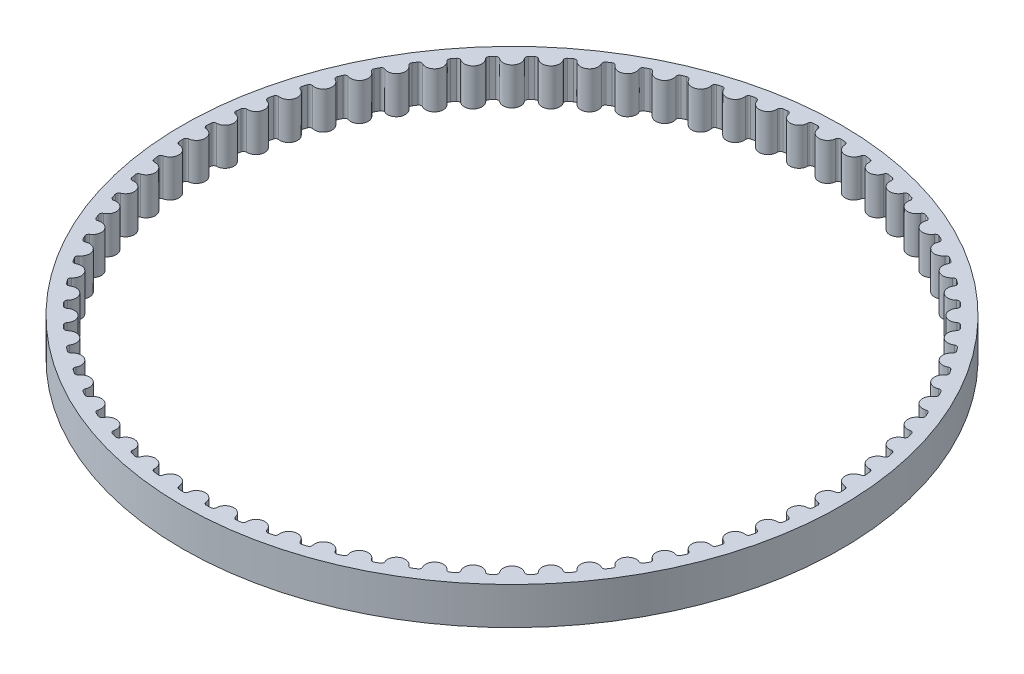
from build123d import *

# Parameters (mm, degrees)
SKETCH1_R           = 35.296467708
BOSS_EXTRUDE1_DEPTH = 4


with BuildPart() as part:
    # Sketch1 → Boss-Extrude1 (new body)
    with BuildSketch(Plane(origin=(0, 0, 0), x_dir=(1, 0, 0), z_dir=(0, 1, 0))):
        Circle(SKETCH1_R)
        with BuildLine():
            ThreePointArc((-1.718362432, -33.953012343), (-1.482905094, -33.964110604), (-1.247376465, -33.973576034))
            ThreePointArc((-1.247376465, -33.973576034), (-1.0405584, -33.900708364), (-0.93907482, -33.706326028))
            ThreePointArc((-0.93907482, -33.706326028), (0, -32.861621383), (0.93907482, -33.706326028))
            ThreePointArc((0.93907482, -33.706326028), (1.0405584, -33.900708364), (1.247376465, -33.973576034))
            ThreePointArc((1.247376465, -33.973576034), (1.482905094, -33.964110604), (1.718362432, -33.953012343))
            ThreePointArc((1.718362432, -33.953012343), (1.918042656, -33.862396574), (2.002198523, -33.659909045))
            ThreePointArc((2.002198523, -33.659909045), (2.864079019, -32.736572992), (3.873201237, -33.496217518))
            ThreePointArc((3.873201237, -33.496217518), (3.991240178, -33.681015294), (4.203622074, -33.735580298))
            ThreePointArc((4.203622074, -33.735580298), (4.437429479, -33.705623214), (4.671023553, -33.674045726))
            ThreePointArc((4.671023553, -33.674045726), (4.862046249, -33.5663715), (4.928233927, -33.35731983))
            ThreePointArc((4.928233927, -33.35731983), (5.706360668, -32.362379514), (6.777850254, -33.031182567))
            ThreePointArc((6.777850254, -33.031182567), (6.911546209, -33.20498936), (7.127875581, -33.240836426))
            ThreePointArc((7.127875581, -33.240836426), (7.358182346, -33.190615679), (7.588135365, -33.138799289))
            ThreePointArc((7.588135365, -33.138799289), (7.769046735, -33.01488607), (7.816762495, -32.800861268))
            ThreePointArc((7.816762495, -32.800861268), (8.505213467, -31.741888787), (9.630915738, -32.314760372))
            ThreePointArc((9.630915738, -32.314760372), (9.779251199, -32.476253407), (9.997881651, -32.493109717))
            ThreePointArc((9.997881651, -32.493109717), (10.222935002, -32.423007519), (10.447496885, -32.351346579))
            ThreePointArc((10.447496885, -32.351346579), (10.616920084, -32.212137422), (10.64580078, -31.994768347))
            ThreePointArc((10.64580078, -31.994768347), (11.239336455, -30.87982312), (12.410684138, -31.352403338))
            ThreePointArc((12.410684138, -31.352403338), (12.572530184, -31.500353556), (12.791797804, -31.498090824))
            ThreePointArc((12.791797804, -31.498090824), (13.009884951, -31.408640693), (13.227346645, -31.317680587))
            ThreePointArc((13.227346645, -31.317680587), (13.38399226, -31.164234959), (13.393818094, -30.94517592))
            ThreePointArc((13.393818094, -30.94517592), (13.887921307, -29.782743354), (15.095999738, -30.151435584))
            ThreePointArc((15.095999738, -30.151435584), (15.270124621, -30.284716994), (15.488360653, -30.26335244))
            ThreePointArc((15.488360653, -30.26335244), (15.697821819, -30.155235147), (15.90652831, -30.045668136))
            ThreePointArc((15.90652831, -30.045668136), (16.049204174, -29.87915385), (16.039900364, -29.660072019))
            ThreePointArc((16.039900364, -29.660072019), (16.430810691, -28.458998927), (17.666425664, -28.720997199))
            ThreePointArc((17.666425664, -28.720997199), (17.851504191, -28.83859545), (18.067047724, -28.798291671))
            ThreePointArc((18.067047724, -28.798291671), (18.266288785, -28.672330053), (18.46465169, -28.544990008))
            ThreePointArc((18.46465169, -28.544990008), (18.592271953, -28.366674338), (18.563909307, -28.14923706))
            ThreePointArc((18.563909307, -28.14923706), (18.848651685, -26.918664334), (20.102399424, -27.071974683))
            ThreePointArc((20.102399424, -27.071974683), (20.297023034, -27.172994781), (20.508233653, -27.114058513))
            ThreePointArc((20.508233653, -27.114058513), (20.695738263, -26.971211214), (20.882247922, -26.827067271))
            ThreePointArc((20.882247922, -26.827067271), (20.993841316, -26.638307307), (20.946635692, -26.424169411))
            ThreePointArc((20.946635692, -26.424169411), (21.123043059, -25.173462452), (22.385381787, -25.216918093))
            ThreePointArc((22.385381787, -25.216918093), (22.588069276, -25.300591214), (22.793339541, -25.223470998))
            ThreePointArc((22.793339541, -25.223470998), (22.967680677, -25.064825173), (23.140917638, -24.904974352))
            ThreePointArc((23.140917638, -24.904974352), (23.235634871, -24.707206672), (23.16994553, -24.497997877))
            ThreePointArc((23.16994553, -24.497997877), (23.23667532, -23.23667532), (24.497997877, -23.16994553))
            ThreePointArc((24.497997877, -23.16994553), (24.707206672, -23.235634871), (24.904974352, -23.140917638))
            ThreePointArc((24.904974352, -23.140917638), (25.064825173, -22.967680677), (25.223470998, -22.793339541))
            ThreePointArc((25.223470998, -22.793339541), (25.300591214, -22.588069276), (25.216918093, -22.385381787))
            ThreePointArc((25.216918093, -22.385381787), (25.173462452, -21.123043059), (26.424169411, -20.946635692))
            ThreePointArc((26.424169411, -20.946635692), (26.638307307, -20.993841316), (26.827067271, -20.882247922))
            ThreePointArc((26.827067271, -20.882247922), (26.971211214, -20.695738263), (27.114058513, -20.508233653))
            ThreePointArc((27.114058513, -20.508233653), (27.172994781, -20.297023034), (27.071974683, -20.102399424))
            ThreePointArc((27.071974683, -20.102399424), (26.918664334, -18.848651685), (28.14923706, -18.563909307))
            ThreePointArc((28.14923706, -18.563909307), (28.366674338, -18.592271953), (28.544990008, -18.46465169))
            ThreePointArc((28.544990008, -18.46465169), (28.672330053, -18.266288785), (28.798291671, -18.067047724))
            ThreePointArc((28.798291671, -18.067047724), (28.83859545, -17.851504191), (28.720997199, -17.666425664))
            ThreePointArc((28.720997199, -17.666425664), (28.458998927, -16.430810691), (29.660072019, -16.039900364))
            ThreePointArc((29.660072019, -16.039900364), (29.87915385, -16.049204174), (30.045668136, -15.90652831))
            ThreePointArc((30.045668136, -15.90652831), (30.155235147, -15.697821819), (30.26335244, -15.488360653))
            ThreePointArc((30.26335244, -15.488360653), (30.284716994, -15.270124621), (30.151435584, -15.095999738))
            ThreePointArc((30.151435584, -15.095999738), (29.782743354, -13.887921307), (30.94517592, -13.393818094))
            ThreePointArc((30.94517592, -13.393818094), (31.164234959, -13.38399226), (31.317680587, -13.227346645))
            ThreePointArc((31.317680587, -13.227346645), (31.408640693, -13.009884951), (31.498090824, -12.791797804))
            ThreePointArc((31.498090824, -12.791797804), (31.500353556, -12.572530184), (31.352403338, -12.410684138))
            ThreePointArc((31.352403338, -12.410684138), (30.87982312, -11.239336455), (31.994768347, -10.64580078))
            ThreePointArc((31.994768347, -10.64580078), (32.212137422, -10.616920084), (32.351346579, -10.447496885))
            ThreePointArc((32.351346579, -10.447496885), (32.423007519, -10.222935002), (32.493109717, -9.997881651))
            ThreePointArc((32.493109717, -9.997881651), (32.476253407, -9.779251199), (32.314760372, -9.630915738))
            ThreePointArc((32.314760372, -9.630915738), (31.741888787, -8.505213467), (32.800861268, -7.816762495))
            ThreePointArc((32.800861268, -7.816762495), (33.01488607, -7.769046735), (33.138799289, -7.588135365))
            ThreePointArc((33.138799289, -7.588135365), (33.190615679, -7.358182346), (33.240836426, -7.127875581))
            ThreePointArc((33.240836426, -7.127875581), (33.20498936, -6.911546209), (33.031182567, -6.777850254))
            ThreePointArc((33.031182567, -6.777850254), (32.362379514, -5.706360668), (33.35731983, -4.928233927))
            ThreePointArc((33.35731983, -4.928233927), (33.5663715, -4.862046249), (33.674045726, -4.671023553))
            ThreePointArc((33.674045726, -4.671023553), (33.705623214, -4.437429479), (33.735580298, -4.203622074))
            ThreePointArc((33.735580298, -4.203622074), (33.681015294, -3.991240178), (33.496217518, -3.873201237))
            ThreePointArc((33.496217518, -3.873201237), (32.736572992, -2.864079019), (33.659909045, -2.002198523))
            ThreePointArc((33.659909045, -2.002198523), (33.862396574, -1.918042656), (33.953012343, -1.718362432))
            ThreePointArc((33.953012343, -1.718362432), (33.964110604, -1.482905094), (33.973576034, -1.247376465))
            ThreePointArc((33.973576034, -1.247376465), (33.900708364, -1.0405584), (33.706326028, -0.93907482))
            ThreePointArc((33.706326028, -0.93907482), (32.861621383, 0), (33.706326028, 0.93907482))
            ThreePointArc((33.706326028, 0.93907482), (33.900708364, 1.0405584), (33.973576034, 1.247376465))
            ThreePointArc((33.973576034, 1.247376465), (33.964110604, 1.482905094), (33.953012343, 1.718362432))
            ThreePointArc((33.953012343, 1.718362432), (33.862396574, 1.918042656), (33.659909045, 2.002198523))
            ThreePointArc((33.659909045, 2.002198523), (32.736572992, 2.864079019), (33.496217518, 3.873201237))
            ThreePointArc((33.496217518, 3.873201237), (33.681015294, 3.991240178), (33.735580298, 4.203622074))
            ThreePointArc((33.735580298, 4.203622074), (33.705623214, 4.437429479), (33.674045726, 4.671023553))
            ThreePointArc((33.674045726, 4.671023553), (33.5663715, 4.862046249), (33.35731983, 4.928233927))
            ThreePointArc((33.35731983, 4.928233927), (32.362379514, 5.706360668), (33.031182567, 6.777850254))
            ThreePointArc((33.031182567, 6.777850254), (33.20498936, 6.911546209), (33.240836426, 7.127875581))
            ThreePointArc((33.240836426, 7.127875581), (33.190615679, 7.358182346), (33.138799289, 7.588135365))
            ThreePointArc((33.138799289, 7.588135365), (33.01488607, 7.769046735), (32.800861268, 7.816762495))
            ThreePointArc((32.800861268, 7.816762495), (31.741888787, 8.505213467), (32.314760372, 9.630915738))
            ThreePointArc((32.314760372, 9.630915738), (32.476253407, 9.779251199), (32.493109717, 9.997881651))
            ThreePointArc((32.493109717, 9.997881651), (32.423007519, 10.222935002), (32.351346579, 10.447496885))
            ThreePointArc((32.351346579, 10.447496885), (32.212137422, 10.616920084), (31.994768347, 10.64580078))
            ThreePointArc((31.994768347, 10.64580078), (30.87982312, 11.239336455), (31.352403338, 12.410684138))
            ThreePointArc((31.352403338, 12.410684138), (31.500353556, 12.572530184), (31.498090824, 12.791797804))
            ThreePointArc((31.498090824, 12.791797804), (31.408640693, 13.009884951), (31.317680587, 13.227346645))
            ThreePointArc((31.317680587, 13.227346645), (31.164234959, 13.38399226), (30.94517592, 13.393818094))
            ThreePointArc((30.94517592, 13.393818094), (29.782743354, 13.887921307), (30.151435584, 15.095999738))
            ThreePointArc((30.151435584, 15.095999738), (30.284716994, 15.270124621), (30.26335244, 15.488360653))
            ThreePointArc((30.26335244, 15.488360653), (30.155235147, 15.697821819), (30.045668136, 15.90652831))
            ThreePointArc((30.045668136, 15.90652831), (29.87915385, 16.049204174), (29.660072019, 16.039900364))
            ThreePointArc((29.660072019, 16.039900364), (28.458998927, 16.430810691), (28.720997199, 17.666425664))
            ThreePointArc((28.720997199, 17.666425664), (28.83859545, 17.851504191), (28.798291671, 18.067047724))
            ThreePointArc((28.798291671, 18.067047724), (28.672330053, 18.266288785), (28.544990008, 18.46465169))
            ThreePointArc((28.544990008, 18.46465169), (28.366674338, 18.592271953), (28.14923706, 18.563909307))
            ThreePointArc((28.14923706, 18.563909307), (26.918664334, 18.848651685), (27.071974683, 20.102399424))
            ThreePointArc((27.071974683, 20.102399424), (27.172994781, 20.297023034), (27.114058513, 20.508233653))
            ThreePointArc((27.114058513, 20.508233653), (26.971211214, 20.695738263), (26.827067271, 20.882247922))
            ThreePointArc((26.827067271, 20.882247922), (26.638307307, 20.993841316), (26.424169411, 20.946635692))
            ThreePointArc((26.424169411, 20.946635692), (25.173462452, 21.123043059), (25.216918093, 22.385381787))
            ThreePointArc((25.216918093, 22.385381787), (25.300591214, 22.588069276), (25.223470998, 22.793339541))
            ThreePointArc((25.223470998, 22.793339541), (25.064825173, 22.967680677), (24.904974352, 23.140917638))
            ThreePointArc((24.904974352, 23.140917638), (24.707206672, 23.235634871), (24.497997877, 23.16994553))
            ThreePointArc((24.497997877, 23.16994553), (23.23667532, 23.23667532), (23.16994553, 24.497997877))
            ThreePointArc((23.16994553, 24.497997877), (23.235634871, 24.707206672), (23.140917638, 24.904974352))
            ThreePointArc((23.140917638, 24.904974352), (22.967680677, 25.064825173), (22.793339541, 25.223470998))
            ThreePointArc((22.793339541, 25.223470998), (22.588069276, 25.300591214), (22.385381787, 25.216918093))
            ThreePointArc((22.385381787, 25.216918093), (21.123043059, 25.173462452), (20.946635692, 26.424169411))
            ThreePointArc((20.946635692, 26.424169411), (20.993841316, 26.638307307), (20.882247922, 26.827067271))
            ThreePointArc((20.882247922, 26.827067271), (20.695738263, 26.971211214), (20.508233653, 27.114058513))
            ThreePointArc((20.508233653, 27.114058513), (20.297023034, 27.172994781), (20.102399424, 27.071974683))
            ThreePointArc((20.102399424, 27.071974683), (18.848651685, 26.918664334), (18.563909307, 28.14923706))
            ThreePointArc((18.563909307, 28.14923706), (18.592271953, 28.366674338), (18.46465169, 28.544990008))
            ThreePointArc((18.46465169, 28.544990008), (18.266288785, 28.672330053), (18.067047724, 28.798291671))
            ThreePointArc((18.067047724, 28.798291671), (17.851504191, 28.83859545), (17.666425664, 28.720997199))
            ThreePointArc((17.666425664, 28.720997199), (16.430810691, 28.458998927), (16.039900364, 29.660072019))
            ThreePointArc((16.039900364, 29.660072019), (16.049204174, 29.87915385), (15.90652831, 30.045668136))
            ThreePointArc((15.90652831, 30.045668136), (15.697821819, 30.155235147), (15.488360653, 30.26335244))
            ThreePointArc((15.488360653, 30.26335244), (15.270124621, 30.284716994), (15.095999738, 30.151435584))
            ThreePointArc((15.095999738, 30.151435584), (13.887921307, 29.782743354), (13.393818094, 30.94517592))
            ThreePointArc((13.393818094, 30.94517592), (13.38399226, 31.164234959), (13.227346645, 31.317680587))
            ThreePointArc((13.227346645, 31.317680587), (13.009884951, 31.408640693), (12.791797804, 31.498090824))
            ThreePointArc((12.791797804, 31.498090824), (12.572530184, 31.500353556), (12.410684138, 31.352403338))
            ThreePointArc((12.410684138, 31.352403338), (11.239336455, 30.87982312), (10.64580078, 31.994768347))
            ThreePointArc((10.64580078, 31.994768347), (10.616920084, 32.212137422), (10.447496885, 32.351346579))
            ThreePointArc((10.447496885, 32.351346579), (10.222935002, 32.423007519), (9.997881651, 32.493109717))
            ThreePointArc((9.997881651, 32.493109717), (9.779251199, 32.476253407), (9.630915738, 32.314760372))
            ThreePointArc((9.630915738, 32.314760372), (8.505213467, 31.741888787), (7.816762495, 32.800861268))
            ThreePointArc((7.816762495, 32.800861268), (7.769046735, 33.01488607), (7.588135365, 33.138799289))
            ThreePointArc((7.588135365, 33.138799289), (7.358182346, 33.190615679), (7.127875581, 33.240836426))
            ThreePointArc((7.127875581, 33.240836426), (6.911546209, 33.20498936), (6.777850254, 33.031182567))
            ThreePointArc((6.777850254, 33.031182567), (5.706360668, 32.362379514), (4.928233927, 33.35731983))
            ThreePointArc((4.928233927, 33.35731983), (4.862046249, 33.5663715), (4.671023553, 33.674045726))
            ThreePointArc((4.671023553, 33.674045726), (4.437429479, 33.705623214), (4.203622074, 33.735580298))
            ThreePointArc((4.203622074, 33.735580298), (3.991240178, 33.681015294), (3.873201237, 33.496217518))
            ThreePointArc((3.873201237, 33.496217518), (2.864079019, 32.736572992), (2.002198523, 33.659909045))
            ThreePointArc((2.002198523, 33.659909045), (1.918042656, 33.862396574), (1.718362432, 33.953012343))
            ThreePointArc((1.718362432, 33.953012343), (1.482905094, 33.964110604), (1.247376465, 33.973576034))
            ThreePointArc((1.247376465, 33.973576034), (1.0405584, 33.900708364), (0.93907482, 33.706326028))
            ThreePointArc((0.93907482, 33.706326028), (0, 32.861621383), (-0.93907482, 33.706326028))
            ThreePointArc((-0.93907482, 33.706326028), (-1.0405584, 33.900708364), (-1.247376465, 33.973576034))
            ThreePointArc((-1.247376465, 33.973576034), (-1.482905094, 33.964110604), (-1.718362432, 33.953012343))
            ThreePointArc((-1.718362432, 33.953012343), (-1.918042656, 33.862396574), (-2.002198523, 33.659909045))
            ThreePointArc((-2.002198523, 33.659909045), (-2.864079019, 32.736572992), (-3.873201237, 33.496217518))
            ThreePointArc((-3.873201237, 33.496217518), (-3.991240178, 33.681015294), (-4.203622074, 33.735580298))
            ThreePointArc((-4.203622074, 33.735580298), (-4.437429479, 33.705623214), (-4.671023553, 33.674045726))
            ThreePointArc((-4.671023553, 33.674045726), (-4.862046249, 33.5663715), (-4.928233927, 33.35731983))
            ThreePointArc((-4.928233927, 33.35731983), (-5.706360668, 32.362379514), (-6.777850254, 33.031182567))
            ThreePointArc((-6.777850254, 33.031182567), (-6.911546209, 33.20498936), (-7.127875581, 33.240836426))
            ThreePointArc((-7.127875581, 33.240836426), (-7.358182346, 33.190615679), (-7.588135365, 33.138799289))
            ThreePointArc((-7.588135365, 33.138799289), (-7.769046735, 33.01488607), (-7.816762495, 32.800861268))
            ThreePointArc((-7.816762495, 32.800861268), (-8.505213467, 31.741888787), (-9.630915738, 32.314760372))
            ThreePointArc((-9.630915738, 32.314760372), (-9.779251199, 32.476253407), (-9.997881651, 32.493109717))
            ThreePointArc((-9.997881651, 32.493109717), (-10.222935002, 32.423007519), (-10.447496885, 32.351346579))
            ThreePointArc((-10.447496885, 32.351346579), (-10.616920084, 32.212137422), (-10.64580078, 31.994768347))
            ThreePointArc((-10.64580078, 31.994768347), (-11.239336455, 30.87982312), (-12.410684138, 31.352403338))
            ThreePointArc((-12.410684138, 31.352403338), (-12.572530184, 31.500353556), (-12.791797804, 31.498090824))
            ThreePointArc((-12.791797804, 31.498090824), (-13.009884951, 31.408640693), (-13.227346645, 31.317680587))
            ThreePointArc((-13.227346645, 31.317680587), (-13.38399226, 31.164234959), (-13.393818094, 30.94517592))
            ThreePointArc((-13.393818094, 30.94517592), (-13.887921307, 29.782743354), (-15.095999738, 30.151435584))
            ThreePointArc((-15.095999738, 30.151435584), (-15.270124621, 30.284716994), (-15.488360653, 30.26335244))
            ThreePointArc((-15.488360653, 30.26335244), (-15.697821819, 30.155235147), (-15.90652831, 30.045668136))
            ThreePointArc((-15.90652831, 30.045668136), (-16.049204174, 29.87915385), (-16.039900364, 29.660072019))
            ThreePointArc((-16.039900364, 29.660072019), (-16.430810691, 28.458998927), (-17.666425664, 28.720997199))
            ThreePointArc((-17.666425664, 28.720997199), (-17.851504191, 28.83859545), (-18.067047724, 28.798291671))
            ThreePointArc((-18.067047724, 28.798291671), (-18.266288785, 28.672330053), (-18.46465169, 28.544990008))
            ThreePointArc((-18.46465169, 28.544990008), (-18.592271953, 28.366674338), (-18.563909307, 28.14923706))
            ThreePointArc((-18.563909307, 28.14923706), (-18.848651685, 26.918664334), (-20.102399424, 27.071974683))
            ThreePointArc((-20.102399424, 27.071974683), (-20.297023034, 27.172994781), (-20.508233653, 27.114058513))
            ThreePointArc((-20.508233653, 27.114058513), (-20.695738263, 26.971211214), (-20.882247922, 26.827067271))
            ThreePointArc((-20.882247922, 26.827067271), (-20.993841316, 26.638307307), (-20.946635692, 26.424169411))
            ThreePointArc((-20.946635692, 26.424169411), (-21.123043059, 25.173462452), (-22.385381787, 25.216918093))
            ThreePointArc((-22.385381787, 25.216918093), (-22.588069276, 25.300591214), (-22.793339541, 25.223470998))
            ThreePointArc((-22.793339541, 25.223470998), (-22.967680677, 25.064825173), (-23.140917638, 24.904974352))
            ThreePointArc((-23.140917638, 24.904974352), (-23.235634871, 24.707206672), (-23.16994553, 24.497997877))
            ThreePointArc((-23.16994553, 24.497997877), (-23.23667532, 23.23667532), (-24.497997877, 23.16994553))
            ThreePointArc((-24.497997877, 23.16994553), (-24.707206672, 23.235634871), (-24.904974352, 23.140917638))
            ThreePointArc((-24.904974352, 23.140917638), (-25.064825173, 22.967680677), (-25.223470998, 22.793339541))
            ThreePointArc((-25.223470998, 22.793339541), (-25.300591214, 22.588069276), (-25.216918093, 22.385381787))
            ThreePointArc((-25.216918093, 22.385381787), (-25.173462452, 21.123043059), (-26.424169411, 20.946635692))
            ThreePointArc((-26.424169411, 20.946635692), (-26.638307307, 20.993841316), (-26.827067271, 20.882247922))
            ThreePointArc((-26.827067271, 20.882247922), (-26.971211214, 20.695738263), (-27.114058513, 20.508233653))
            ThreePointArc((-27.114058513, 20.508233653), (-27.172994781, 20.297023034), (-27.071974683, 20.102399424))
            ThreePointArc((-27.071974683, 20.102399424), (-26.918664334, 18.848651685), (-28.14923706, 18.563909307))
            ThreePointArc((-28.14923706, 18.563909307), (-28.366674338, 18.592271953), (-28.544990008, 18.46465169))
            ThreePointArc((-28.544990008, 18.46465169), (-28.672330053, 18.266288785), (-28.798291671, 18.067047724))
            ThreePointArc((-28.798291671, 18.067047724), (-28.83859545, 17.851504191), (-28.720997199, 17.666425664))
            ThreePointArc((-28.720997199, 17.666425664), (-28.458998927, 16.430810691), (-29.660072019, 16.039900364))
            ThreePointArc((-29.660072019, 16.039900364), (-29.87915385, 16.049204174), (-30.045668136, 15.90652831))
            ThreePointArc((-30.045668136, 15.90652831), (-30.155235147, 15.697821819), (-30.26335244, 15.488360653))
            ThreePointArc((-30.26335244, 15.488360653), (-30.284716994, 15.270124621), (-30.151435584, 15.095999738))
            ThreePointArc((-30.151435584, 15.095999738), (-29.782743354, 13.887921307), (-30.94517592, 13.393818094))
            ThreePointArc((-30.94517592, 13.393818094), (-31.164234959, 13.38399226), (-31.317680587, 13.227346645))
            ThreePointArc((-31.317680587, 13.227346645), (-31.408640693, 13.009884951), (-31.498090824, 12.791797804))
            ThreePointArc((-31.498090824, 12.791797804), (-31.500353556, 12.572530184), (-31.352403338, 12.410684138))
            ThreePointArc((-31.352403338, 12.410684138), (-30.87982312, 11.239336455), (-31.994768347, 10.64580078))
            ThreePointArc((-31.994768347, 10.64580078), (-32.212137422, 10.616920084), (-32.351346579, 10.447496885))
            ThreePointArc((-32.351346579, 10.447496885), (-32.423007519, 10.222935002), (-32.493109717, 9.997881651))
            ThreePointArc((-32.493109717, 9.997881651), (-32.476253407, 9.779251199), (-32.314760372, 9.630915738))
            ThreePointArc((-32.314760372, 9.630915738), (-31.741888787, 8.505213467), (-32.800861268, 7.816762495))
            ThreePointArc((-32.800861268, 7.816762495), (-33.01488607, 7.769046735), (-33.138799289, 7.588135365))
            ThreePointArc((-33.138799289, 7.588135365), (-33.190615679, 7.358182346), (-33.240836426, 7.127875581))
            ThreePointArc((-33.240836426, 7.127875581), (-33.20498936, 6.911546209), (-33.031182567, 6.777850254))
            ThreePointArc((-33.031182567, 6.777850254), (-32.362379514, 5.706360668), (-33.35731983, 4.928233927))
            ThreePointArc((-33.35731983, 4.928233927), (-33.5663715, 4.862046249), (-33.674045726, 4.671023553))
            ThreePointArc((-33.674045726, 4.671023553), (-33.705623214, 4.437429479), (-33.735580298, 4.203622074))
            ThreePointArc((-33.735580298, 4.203622074), (-33.681015294, 3.991240178), (-33.496217518, 3.873201237))
            ThreePointArc((-33.496217518, 3.873201237), (-32.736572992, 2.864079019), (-33.659909045, 2.002198523))
            ThreePointArc((-33.659909045, 2.002198523), (-33.862396574, 1.918042656), (-33.953012343, 1.718362432))
            ThreePointArc((-33.953012343, 1.718362432), (-33.964110604, 1.482905094), (-33.973576034, 1.247376465))
            ThreePointArc((-33.973576034, 1.247376465), (-33.900708364, 1.0405584), (-33.706326028, 0.93907482))
            ThreePointArc((-33.706326028, 0.93907482), (-32.861621383, 0), (-33.706326028, -0.93907482))
            ThreePointArc((-33.706326028, -0.93907482), (-33.900708364, -1.0405584), (-33.973576034, -1.247376465))
            ThreePointArc((-33.973576034, -1.247376465), (-33.964110604, -1.482905094), (-33.953012343, -1.718362432))
            ThreePointArc((-33.953012343, -1.718362432), (-33.862396574, -1.918042656), (-33.659909045, -2.002198523))
            ThreePointArc((-33.659909045, -2.002198523), (-32.736572992, -2.864079019), (-33.496217518, -3.873201237))
            ThreePointArc((-33.496217518, -3.873201237), (-33.681015294, -3.991240178), (-33.735580298, -4.203622074))
            ThreePointArc((-33.735580298, -4.203622074), (-33.705623214, -4.437429479), (-33.674045726, -4.671023553))
            ThreePointArc((-33.674045726, -4.671023553), (-33.5663715, -4.862046249), (-33.35731983, -4.928233927))
            ThreePointArc((-33.35731983, -4.928233927), (-32.362379514, -5.706360668), (-33.031182567, -6.777850254))
            ThreePointArc((-33.031182567, -6.777850254), (-33.20498936, -6.911546209), (-33.240836426, -7.127875581))
            ThreePointArc((-33.240836426, -7.127875581), (-33.190615679, -7.358182346), (-33.138799289, -7.588135365))
            ThreePointArc((-33.138799289, -7.588135365), (-33.01488607, -7.769046735), (-32.800861268, -7.816762495))
            ThreePointArc((-32.800861268, -7.816762495), (-31.741888787, -8.505213467), (-32.314760372, -9.630915738))
            ThreePointArc((-32.314760372, -9.630915738), (-32.476253407, -9.779251199), (-32.493109717, -9.997881651))
            ThreePointArc((-32.493109717, -9.997881651), (-32.423007519, -10.222935002), (-32.351346579, -10.447496885))
            ThreePointArc((-32.351346579, -10.447496885), (-32.212137422, -10.616920084), (-31.994768347, -10.64580078))
            ThreePointArc((-31.994768347, -10.64580078), (-30.87982312, -11.239336455), (-31.352403338, -12.410684138))
            ThreePointArc((-31.352403338, -12.410684138), (-31.500353556, -12.572530184), (-31.498090824, -12.791797804))
            ThreePointArc((-31.498090824, -12.791797804), (-31.408640693, -13.009884951), (-31.317680587, -13.227346645))
            ThreePointArc((-31.317680587, -13.227346645), (-31.164234959, -13.38399226), (-30.94517592, -13.393818094))
            ThreePointArc((-30.94517592, -13.393818094), (-29.782743354, -13.887921307), (-30.151435584, -15.095999738))
            ThreePointArc((-30.151435584, -15.095999738), (-30.284716994, -15.270124621), (-30.26335244, -15.488360653))
            ThreePointArc((-30.26335244, -15.488360653), (-30.155235147, -15.697821819), (-30.045668136, -15.90652831))
            ThreePointArc((-30.045668136, -15.90652831), (-29.87915385, -16.049204174), (-29.660072019, -16.039900364))
            ThreePointArc((-29.660072019, -16.039900364), (-28.458998927, -16.430810691), (-28.720997199, -17.666425664))
            ThreePointArc((-28.720997199, -17.666425664), (-28.83859545, -17.851504191), (-28.798291671, -18.067047724))
            ThreePointArc((-28.798291671, -18.067047724), (-28.672330053, -18.266288785), (-28.544990008, -18.46465169))
            ThreePointArc((-28.544990008, -18.46465169), (-28.366674338, -18.592271953), (-28.14923706, -18.563909307))
            ThreePointArc((-28.14923706, -18.563909307), (-26.918664334, -18.848651685), (-27.071974683, -20.102399424))
            ThreePointArc((-27.071974683, -20.102399424), (-27.172994781, -20.297023034), (-27.114058513, -20.508233653))
            ThreePointArc((-27.114058513, -20.508233653), (-26.971211214, -20.695738263), (-26.827067271, -20.882247922))
            ThreePointArc((-26.827067271, -20.882247922), (-26.638307307, -20.993841316), (-26.424169411, -20.946635692))
            ThreePointArc((-26.424169411, -20.946635692), (-25.173462452, -21.123043059), (-25.216918093, -22.385381787))
            ThreePointArc((-25.216918093, -22.385381787), (-25.300591214, -22.588069276), (-25.223470998, -22.793339541))
            ThreePointArc((-25.223470998, -22.793339541), (-25.064825173, -22.967680677), (-24.904974352, -23.140917638))
            ThreePointArc((-24.904974352, -23.140917638), (-24.707206672, -23.235634871), (-24.497997877, -23.16994553))
            ThreePointArc((-24.497997877, -23.16994553), (-23.23667532, -23.23667532), (-23.16994553, -24.497997877))
            ThreePointArc((-23.16994553, -24.497997877), (-23.235634871, -24.707206672), (-23.140917638, -24.904974352))
            ThreePointArc((-23.140917638, -24.904974352), (-22.967680677, -25.064825173), (-22.793339541, -25.223470998))
            ThreePointArc((-22.793339541, -25.223470998), (-22.588069276, -25.300591214), (-22.385381787, -25.216918093))
            ThreePointArc((-22.385381787, -25.216918093), (-21.123043059, -25.173462452), (-20.946635692, -26.424169411))
            ThreePointArc((-20.946635692, -26.424169411), (-20.993841316, -26.638307307), (-20.882247922, -26.827067271))
            ThreePointArc((-20.882247922, -26.827067271), (-20.695738263, -26.971211214), (-20.508233653, -27.114058513))
            ThreePointArc((-20.508233653, -27.114058513), (-20.297023034, -27.172994781), (-20.102399424, -27.071974683))
            ThreePointArc((-20.102399424, -27.071974683), (-18.848651685, -26.918664334), (-18.563909307, -28.14923706))
            ThreePointArc((-18.563909307, -28.14923706), (-18.592271953, -28.366674338), (-18.46465169, -28.544990008))
            ThreePointArc((-18.46465169, -28.544990008), (-18.266288785, -28.672330053), (-18.067047724, -28.798291671))
            ThreePointArc((-18.067047724, -28.798291671), (-17.851504191, -28.83859545), (-17.666425664, -28.720997199))
            ThreePointArc((-17.666425664, -28.720997199), (-16.430810691, -28.458998927), (-16.039900364, -29.660072019))
            ThreePointArc((-16.039900364, -29.660072019), (-16.049204174, -29.87915385), (-15.90652831, -30.045668136))
            ThreePointArc((-15.90652831, -30.045668136), (-15.697821819, -30.155235147), (-15.488360653, -30.26335244))
            ThreePointArc((-15.488360653, -30.26335244), (-15.270124621, -30.284716994), (-15.095999738, -30.151435584))
            ThreePointArc((-15.095999738, -30.151435584), (-13.887921307, -29.782743354), (-13.393818094, -30.94517592))
            ThreePointArc((-13.393818094, -30.94517592), (-13.38399226, -31.164234959), (-13.227346645, -31.317680587))
            ThreePointArc((-13.227346645, -31.317680587), (-13.009884951, -31.408640693), (-12.791797804, -31.498090824))
            ThreePointArc((-12.791797804, -31.498090824), (-12.572530184, -31.500353556), (-12.410684138, -31.352403338))
            ThreePointArc((-12.410684138, -31.352403338), (-11.239336455, -30.87982312), (-10.64580078, -31.994768347))
            ThreePointArc((-10.64580078, -31.994768347), (-10.616920084, -32.212137422), (-10.447496885, -32.351346579))
            ThreePointArc((-10.447496885, -32.351346579), (-10.222935002, -32.423007519), (-9.997881651, -32.493109717))
            ThreePointArc((-9.997881651, -32.493109717), (-9.779251199, -32.476253407), (-9.630915738, -32.314760372))
            ThreePointArc((-9.630915738, -32.314760372), (-8.505213467, -31.741888787), (-7.816762495, -32.800861268))
            ThreePointArc((-7.816762495, -32.800861268), (-7.769046735, -33.01488607), (-7.588135365, -33.138799289))
            ThreePointArc((-7.588135365, -33.138799289), (-7.358182346, -33.190615679), (-7.127875581, -33.240836426))
            ThreePointArc((-7.127875581, -33.240836426), (-6.911546209, -33.20498936), (-6.777850254, -33.031182567))
            ThreePointArc((-6.777850254, -33.031182567), (-5.706360668, -32.362379514), (-4.928233927, -33.35731983))
            ThreePointArc((-4.928233927, -33.35731983), (-4.862046249, -33.5663715), (-4.671023553, -33.674045726))
            ThreePointArc((-4.671023553, -33.674045726), (-4.437429479, -33.705623214), (-4.203622074, -33.735580298))
            ThreePointArc((-4.203622074, -33.735580298), (-3.991240178, -33.681015294), (-3.873201237, -33.496217518))
            ThreePointArc((-3.873201237, -33.496217518), (-2.864079019, -32.736572992), (-2.002198523, -33.659909045))
            ThreePointArc((-2.002198523, -33.659909045), (-1.918042656, -33.862396574), (-1.718362432, -33.953012343))
        make_face(mode=Mode.SUBTRACT)
    extrude(amount=BOSS_EXTRUDE1_DEPTH)


solid = part.part
